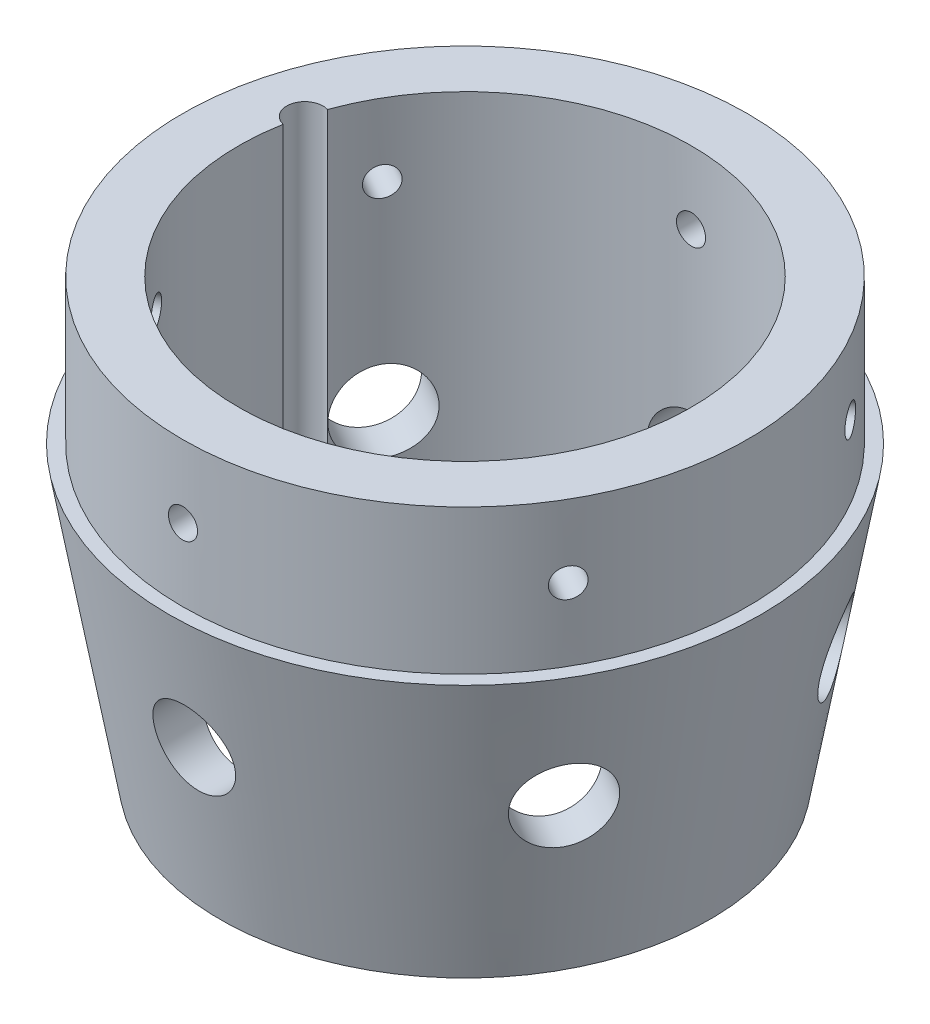
from build123d import *

# Parameters (mm, degrees)
TAP_DRILL_FOR_1_4_20_TAP1_REACH     = 139.089
TAP_DRILL_FOR_1_4_20_TAP1_BORE_R    = 2.5527
CIRPATTERN1_COUNT                   = 6
SKETCH12_R                          = 3.175
CUT_EXTRUDE2_DEPTH                  = 106.81736339
F_9_16_0_5625_DIAMETER_HOLE7_REACH  = 159.848
F_9_16_0_5625_DIAMETER_HOLE7_BORE_R = 7.14375
CIRPATTERN2_COUNT                   = 6


with BuildPart() as part:
    # Sketch1 → Revolve1 (revolve)
    with BuildSketch(Plane.XY, mode=Mode.PRIVATE) as revolve1_sk:
        Polygon((-51.9176, 50.8), (-49.53, 50.8), (-49.53, 76.2), (-39.7256, 76.2), (-39.7256, 0), (-42.96018938, 0), align=None)
    revolve(revolve1_sk.sketch.rotate(Axis((0, 0, 0), (0, 1, 0)), 270), axis=Axis((0, 0, 0), (0, 1, 0)))

    # Tap Drill for 1/4-20 Tap1 bore → Tap Drill for 1/4-20 Tap1 (cut, up to next)
    with BuildSketch(Plane.XY.offset(49.53), mode=Mode.PRIVATE) as tap_drill_for_1_4_20_tap1_sk1:
        with Locations((0, 63.5)):
            Circle(TAP_DRILL_FOR_1_4_20_TAP1_BORE_R)
    tap_drill_for_1_4_20_tap1_tool1 = extrude(tap_drill_for_1_4_20_tap1_sk1.sketch, amount=-TAP_DRILL_FOR_1_4_20_TAP1_REACH, mode=Mode.PRIVATE) & part.part
    tap_drill_for_1_4_20_tap1 = tap_drill_for_1_4_20_tap1_tool1.solids().sort_by_distance((0, 63.5, 49.53))[0]
    add(tap_drill_for_1_4_20_tap1, mode=Mode.SUBTRACT)

    # CirPattern1: Tap Drill for 1/4-20 Tap1 ×6 about axis
    cirpattern1_axis = Axis((0, 0, 0), (0, -1, 0))
    for i in range(1, CIRPATTERN1_COUNT):
        add(tap_drill_for_1_4_20_tap1.rotate(cirpattern1_axis, i * 360 / CIRPATTERN1_COUNT), mode=Mode.SUBTRACT)

    # Sketch12 → Cut-Extrude2 (cut, through all)
    with BuildSketch(Plane(origin=(0, 76.2, 0), x_dir=(1, 0, 0), z_dir=(0, 1, 0))):
        with Locations((-38.371983005, 10.281741858)):
            Circle(SKETCH12_R)
    extrude(amount=-CUT_EXTRUDE2_DEPTH, mode=Mode.SUBTRACT)

    # 9/16 (0.5625) Diameter Hole7 bore → 9/16 (0.5625) Diameter Hole7 (cut, up to next)
    with BuildSketch(Plane(origin=(0, 0, -76.2), x_dir=(1, 0, 0), z_dir=(0, 0, -1)), mode=Mode.PRIVATE) as f_9_16_0_5625_diameter_hole7_sk1:
        with Locations((0, -28.6126174)):
            Circle(F_9_16_0_5625_DIAMETER_HOLE7_BORE_R)
    f_9_16_0_5625_diameter_hole7_tool1 = extrude(f_9_16_0_5625_diameter_hole7_sk1.sketch, amount=-F_9_16_0_5625_DIAMETER_HOLE7_REACH, mode=Mode.PRIVATE) & part.part
    f_9_16_0_5625_diameter_hole7 = f_9_16_0_5625_diameter_hole7_tool1.solids().sort_by_distance((0, 28.612617, -76.2))[0]
    add(f_9_16_0_5625_diameter_hole7, mode=Mode.SUBTRACT)

    # CirPattern2: 9/16 (0.5625) Diameter Hole7 ×6 about axis
    cirpattern2_axis = Axis((0, 80.01, 0), (0, -1, 0))
    for i in range(1, CIRPATTERN2_COUNT):
        add(f_9_16_0_5625_diameter_hole7.rotate(cirpattern2_axis, i * 360 / CIRPATTERN2_COUNT), mode=Mode.SUBTRACT)


solid = part.part
